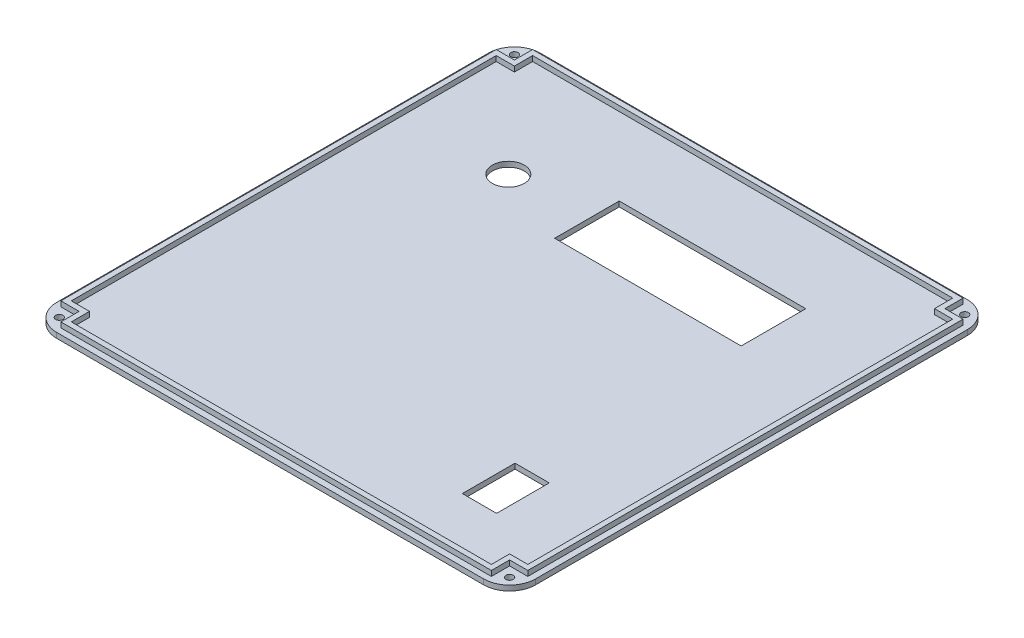
from build123d import *

# Parameters (mm, degrees)
BOSS_EXTRUDE1_DEPTH = 2
SKETCH13_W          = 184
SKETCH13_H          = 185.84
SKETCH13_R          = 1.4
BOSS_EXTRUDE6_DEPTH = 2
FILLET3_R           = 10
CUT_EXTRUDE9_REACH  = 6
SKETCH14_R          = 6.12
SKETCH14_W          = 71.67
SKETCH14_H          = 24.82
SKETCH14_W_2        = 13.16
SKETCH14_H_2        = 20.24


with BuildPart() as part:
    # Sketch1 → Boss-Extrude1 (new body)
    with BuildSketch(Plane(origin=(0, 0, 0), x_dir=(1, 0, 0), z_dir=(0, 1, 0))):
        Polygon((-82.7, -90.62), (82.7, -90.62), (82.7, -83.62), (89.7, -83.62), (89.7, 83.62), (82.7, 83.62), (82.7, 90.62), (-82.7, 90.62), (-82.7, 83.62), (-89.7, 83.62), (-89.7, -83.62), (-82.7, -83.62), align=None)
        Polygon((-80.7, -88.62), (80.7, -88.62), (80.7, -81.62), (87.7, -81.62), (87.7, 81.62), (80.7, 81.62), (80.7, 88.62), (-80.7, 88.62), (-80.7, 81.62), (-87.7, 81.62), (-87.7, -81.62), (-80.7, -81.62), align=None, mode=Mode.SUBTRACT)
    extrude(amount=BOSS_EXTRUDE1_DEPTH)

    # Sketch13 → Boss-Extrude6 (add)
    with BuildSketch(Plane.XZ):
        Rectangle(SKETCH13_W, SKETCH13_H)
        with Locations((-86.5, -87.42)):
            Circle(SKETCH13_R, mode=Mode.SUBTRACT)
        with Locations((86.5, -87.42)):
            Circle(SKETCH13_R, mode=Mode.SUBTRACT)
        with Locations((86.5, 87.42)):
            Circle(SKETCH13_R, mode=Mode.SUBTRACT)
        with Locations((-86.5, 87.42)):
            Circle(SKETCH13_R, mode=Mode.SUBTRACT)
    extrude(amount=BOSS_EXTRUDE6_DEPTH)

    # Fillet3
    fillet3_edges = [part.edges().sort_by_distance(p)[0] for p in [
        (-92, -1, 92.92),
        (-92, -1, -92.92),
        (92, -1, -92.92),
        (92, -1, 92.92),
    ]]
    fillet(fillet3_edges, radius=FILLET3_R)

    # Sketch14 → Cut-Extrude9 (cut, up to next)
    with BuildSketch(Plane.XZ.offset(2), mode=Mode.PRIVATE) as cut_extrude9_sk1:
        with Locations((-47.874498459, -46.46)):
            Circle(SKETCH14_R)
    cut_extrude9_tool1 = extrude(cut_extrude9_sk1.sketch, amount=-CUT_EXTRUDE9_REACH, mode=Mode.PRIVATE) & part.part
    add(cut_extrude9_tool1.solids().sort_by_distance((-47.874498, -2, -46.46))[0], mode=Mode.SUBTRACT)
    # Sketch14 → Cut-Extrude9 (cut, up to next)
    with BuildSketch(Plane.XZ.offset(2), mode=Mode.PRIVATE) as cut_extrude9_sk2:
        with Locations((18.159498459, -46.46)):
            Rectangle(SKETCH14_W, SKETCH14_H)
    cut_extrude9_tool2 = extrude(cut_extrude9_sk2.sketch, amount=-CUT_EXTRUDE9_REACH, mode=Mode.PRIVATE) & part.part
    add(cut_extrude9_tool2.solids().sort_by_distance((18.159498, -2, -46.46))[0], mode=Mode.SUBTRACT)
    # Sketch14 → Cut-Extrude9 (cut, up to next)
    with BuildSketch(Plane.XZ.offset(2), mode=Mode.PRIVATE) as cut_extrude9_sk3:
        with Locations((56.12, 58.5)):
            Rectangle(SKETCH14_W_2, SKETCH14_H_2)
    cut_extrude9_tool3 = extrude(cut_extrude9_sk3.sketch, amount=-CUT_EXTRUDE9_REACH, mode=Mode.PRIVATE) & part.part
    add(cut_extrude9_tool3.solids().sort_by_distance((56.12, -2, 58.5))[0], mode=Mode.SUBTRACT)


solid = part.part
